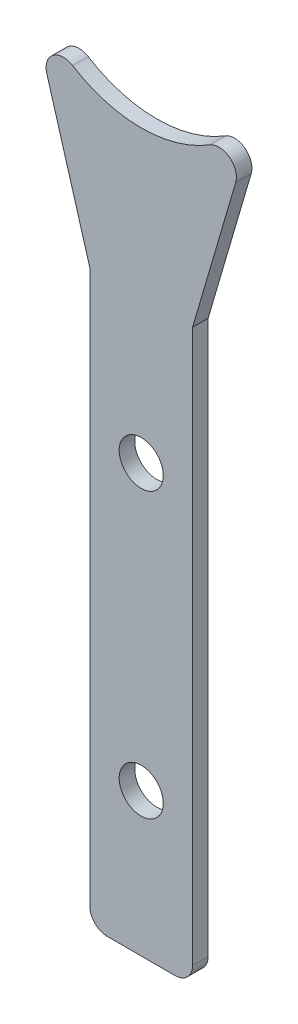
from build123d import *

# Parameters (mm, degrees)
SKETCH1_R            = 2
BOSS_EXTRUDE1_DEPTH  = 1.5875
FILLET2_R            = 1.778
M4_CLEARANCE_HOLE2_D = 4.5


with BuildPart() as part:
    # Sketch1 → Boss-Extrude1 (new body)
    with BuildSketch(Plane.XY):
        with BuildLine():
            Line((-3.078924099, -28.617866551), (2.159951047, -28.617866551))
            Line((2.159951047, -28.617866551), (7.399260817, -28.617866551))
            Line((7.399260817, -28.617866551), (7.399260817, 14.567438128))
            Line((7.399260817, 14.567438128), (7.399260817, 29.567438098))
            Line((7.399260817, 29.567438098), (13.897648784, 51.719401208))
            ThreePointArc((13.897648784, 51.719401208), (2.158996515, 44.568125735), (-9.579655755, 51.719401208))
            Line((-9.579655755, 51.719401208), (-3.078924099, 29.568125765))
            Line((-3.078924099, 29.568125765), (-3.078924099, -28.617866551))
        make_face()
        with BuildLine():
            ThreePointArc((4.159951047, -14.006866551), (3.574164609, -15.421080114), (2.159951047, -16.006866551))
            ThreePointArc((2.159951047, -16.006866551), (0.745737485, -12.592652989), (4.159951047, -14.006866551))
        make_face(mode=Mode.SUBTRACT)
        with Locations((2.159951047, 14.957125769)):
            Circle(SKETCH1_R, mode=Mode.SUBTRACT)
    extrude(amount=BOSS_EXTRUDE1_DEPTH)

    # Fillet2
    fillet2_edges = [part.edges().sort_by_distance(p)[0] for p in [
        (-9.579655755, 51.719401208, 0.79375),
        (13.897648784, 51.719401208, 0.79375),
        (7.399260817, -28.617866551, 0.79375),
        (-3.078924099, -28.617866551, 0.79375),
    ]]
    fillet(fillet2_edges, radius=FILLET2_R)

    # M4 Clearance Hole2 (through all)
    with Locations(Plane.XY.offset(1.5875)):
        with Locations((2.159951047, 14.957125769), (2.159951047, -14.006866551)):
            Hole(M4_CLEARANCE_HOLE2_D / 2)


solid = part.part
